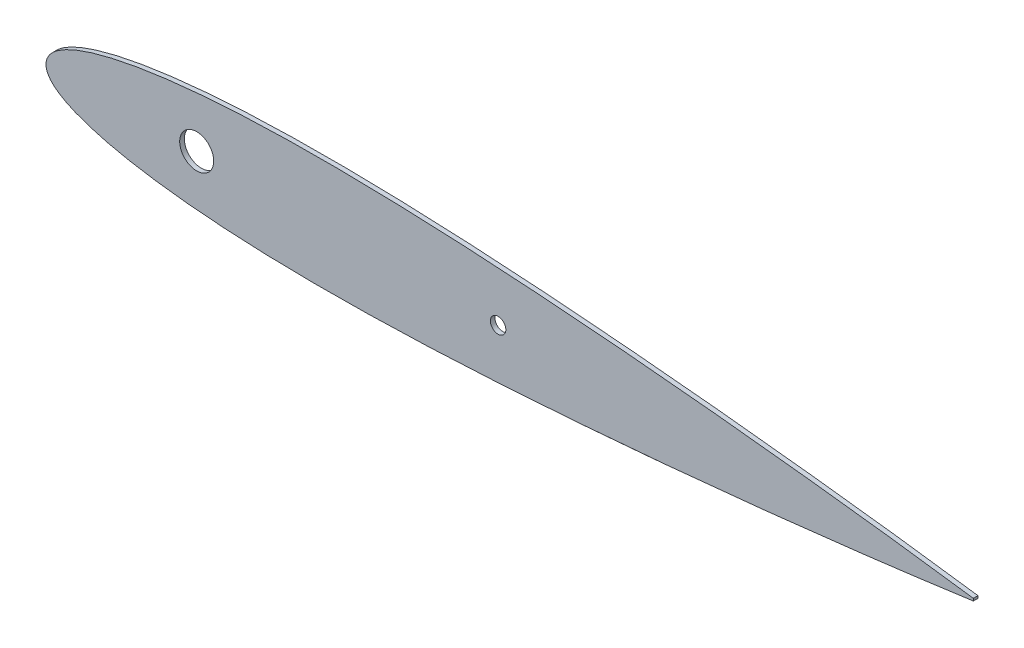
from build123d import *

# Parameters (mm, degrees)
BOSS_EXTRUDE1_DEPTH = 1.5
SKETCH7_R           = 5.5
SKETCH7_R_2         = 2.5
CUT_EXTRUDE7_DEPTH  = 2.5000001


with BuildPart() as part:
    # Sketch5 → Boss-Extrude1 (new body)
    with BuildSketch(Plane.XY):
        with BuildLine():
            Line((300, 0.378000086), (300, -0.378000086))
            add(Edge.make_bspline(
                [(300, 0.378000086), (299.270406258, 0.479445931), (297.234666467, 0.762503927), (293.659648722, 1.257673791), (289.112409325, 1.874242868), (284.080813047, 2.544518018), (278.752039398, 3.238123051), (273.265892957, 3.934947328), (267.705948145, 4.629020993), (262.114554424, 5.313070312), (256.508339042, 5.98219317), (250.891727853, 6.637992315), (245.269544548, 7.281780887), (239.647331656, 7.912234559), (234.025115138, 8.526993981), (228.399071658, 9.126231834), (222.768240123, 9.71307981), (217.135901993, 10.287462144), (211.505390076, 10.846943545), (205.877598449, 11.391645411), (200.251489743, 11.920887329), (194.626396629, 12.434619899), (189.002771954, 12.931914744), (183.381504479, 13.413100625), (177.763197883, 13.876379849), (172.148272526, 14.321240443), (166.537499181, 14.747824264), (160.931704642, 15.154231582), (155.331676028, 15.539104381), (149.737504253, 15.902653172), (144.148652919, 16.241849804), (138.565642978, 16.557424303), (132.990821912, 16.847401378), (127.427400287, 17.110215561), (121.877579225, 17.343895653), (116.340716908, 17.545260794), (110.81543346, 17.712683139), (105.301229225, 17.844501987), (99.800524694, 17.940095883), (94.317389178, 17.996594522), (88.855716162, 18.010128544), (83.418598836, 17.97923792), (78.008430461, 17.899164774), (72.628403778, 17.767037818), (67.282685946, 17.579417922), (61.977310891, 17.331519421), (56.72063582, 17.021036513), (51.525118947, 16.640961845), (46.408145083, 16.190192264), (41.394117392, 15.661672653), (36.515611307, 15.053967199), (31.818948595, 14.365626864), (27.366102973, 13.60347877), (23.235155161, 12.782586344), (19.502578811, 11.920253456), (16.218207008, 11.044600302), (13.389120989, 10.175078564), (10.984863761, 9.333500833), (8.961495446, 8.522064815), (7.267225637, 7.746977759), (5.845985727, 7.010627212), (4.647644075, 6.300635462), (3.62816801, 5.60651494), (2.751841757, 4.926636369), (2.006189751, 4.249918223), (1.390518388, 3.570260302), (0.900932575, 2.890942908), (0.52920759, 2.220219777), (0.260411531, 1.566459291), (0.085644609, 0.931036139), (-0.003577313, 0.308981085), (-0.003577313, -0.308981085), (0.085644609, -0.931036139), (0.260411531, -1.566459291), (0.52920759, -2.220219777), (0.900932575, -2.890942908), (1.390518388, -3.570260302), (2.006189751, -4.249918223), (2.751841757, -4.926636369), (3.62816801, -5.60651494), (4.647644075, -6.300635462), (5.845985727, -7.010627213), (7.267225637, -7.746977757), (8.961495444, -8.522064829), (10.984863772, -9.333500769), (13.389120938, -10.175078867), (16.218207245, -11.044598882), (19.502577721, -11.920259984), (23.235160006, -12.782557313), (27.366065703, -13.603599247), (31.819014163, -14.365116623), (36.515574857, -15.054109513), (41.394123531, -15.66163244), (46.408143388, -16.190203367), (51.525119412, -16.640958803), (56.720635693, -17.021037342), (61.977310926, -17.331519196), (67.282685937, -17.579417983), (72.628403781, -17.767037802), (78.008430461, -17.899164778), (83.418598837, -17.979237918), (88.855716162, -18.010128544), (94.317389178, -17.996594522), (99.800524694, -17.940095883), (105.301229225, -17.844501987), (110.81543346, -17.712683139), (116.340716908, -17.545260794), (121.877579225, -17.343895653), (127.427400287, -17.110215561), (132.990821912, -16.847401378), (138.565642978, -16.557424303), (144.148652919, -16.241849804), (149.737504253, -15.902653172), (155.331676028, -15.539104381), (160.931704642, -15.154231582), (166.537499181, -14.747824264), (172.148272526, -14.321240443), (177.763197883, -13.876379849), (183.381504479, -13.413100625), (189.002771954, -12.931914743), (194.626396629, -12.434619899), (200.251489743, -11.920887329), (205.877598449, -11.391645411), (211.505390076, -10.846943545), (217.135901993, -10.287462144), (222.768240123, -9.71307981), (228.399071658, -9.126231834), (234.025115138, -8.526993981), (239.647331656, -7.912234559), (245.269544548, -7.281780887), (250.891727853, -6.637992315), (256.508339042, -5.98219317), (262.114554424, -5.313070312), (267.705948145, -4.629020993), (273.265892957, -3.934947328), (278.752039398, -3.238123051), (284.080813047, -2.544518018), (289.112409325, -1.874242868), (293.659648722, -1.257673791), (297.234666467, -0.762503927), (299.270406258, -0.47944593), (300, -0.378000086)],
                knots=[0, 0, 0, 0, 0.003612221, 0.010078953, 0.017698618, 0.026115111, 0.034970966, 0.04405038, 0.05323433, 0.06244757, 0.071673993, 0.080921319, 0.090177538, 0.099424342, 0.108664441, 0.117912199, 0.127169502, 0.136426595, 0.145675426, 0.154916495, 0.164153237, 0.173386649, 0.182615736, 0.191838089, 0.201053134, 0.210260393, 0.219458942, 0.228646747, 0.237822316, 0.246985224, 0.256137384, 0.265279416, 0.27440695, 0.283512193, 0.292591781, 0.301646285, 0.310681793, 0.319699068, 0.32869452, 0.33766016, 0.346588583, 0.355477412, 0.364322937, 0.373121614, 0.381867635, 0.390553005, 0.399166026, 0.407689628, 0.416098119, 0.424354887, 0.432412429, 0.440204728, 0.447630505, 0.454563638, 0.460855379, 0.466413319, 0.47122861, 0.475365774, 0.47890126, 0.481915077, 0.484498872, 0.486747127, 0.488741252, 0.490543179, 0.492182104, 0.493672831, 0.495031908, 0.49627906, 0.497424737, 0.498490166, 0.499502758, 0.500497254, 0.501509846, 0.502575275, 0.503720952, 0.504968104, 0.506327181, 0.507817908, 0.509456832, 0.51125876, 0.513252884, 0.51550114, 0.518084934, 0.521098752, 0.524634237, 0.528771401, 0.533586692, 0.539144632, 0.545436374, 0.552369506, 0.5597952, 0.567587571, 0.575645113, 0.583901881, 0.592310372, 0.600833974, 0.609446995, 0.618132365, 0.626878386, 0.635677063, 0.644522588, 0.653411417, 0.66233984, 0.67130548, 0.680300932, 0.689318207, 0.698353715, 0.707408219, 0.716487807, 0.72559305, 0.734720584, 0.743862616, 0.753014776, 0.762177684, 0.771353253, 0.780541058, 0.789739607, 0.798946866, 0.808161911, 0.817384264, 0.826613351, 0.835846763, 0.845083505, 0.854324574, 0.863573405, 0.872830498, 0.882087801, 0.891335559, 0.900575658, 0.909822462, 0.919078681, 0.928326007, 0.93755243, 0.94676567, 0.95594962, 0.965029034, 0.973884889, 0.982301382, 0.989921047, 0.996387779, 1, 1, 1, 1], degree=3))
        make_face()
    extrude(amount=BOSS_EXTRUDE1_DEPTH)

    # Sketch7 → Cut-Extrude7 (cut, through all)
    with BuildSketch(Plane.XY.offset(1.5)):
        with Locations((48.75, 0)):
            Circle(SKETCH7_R)
        with Locations((146.25, 0)):
            Circle(SKETCH7_R_2)
    extrude(amount=-CUT_EXTRUDE7_DEPTH, mode=Mode.SUBTRACT)


solid = part.part
